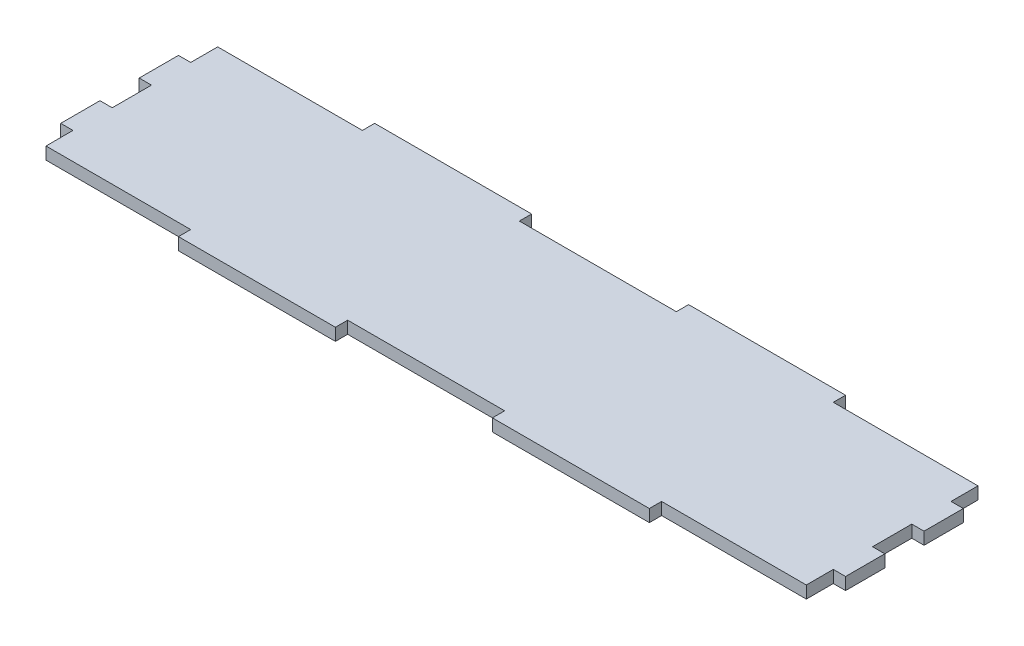
from build123d import *

# Parameters (mm, degrees)
SKETCH1_W           = 203.2
SKETCH1_H           = 50.8
BOSS_EXTRUDE1_DEPTH = 3.175
SKETCH2_W           = 40.64
SKETCH2_H           = 3.175
CUT_EXTRUDE2_DEPTH  = 3.175
LPATTERN1_COUNT     = 3
LPATTERN1_PITCH     = 81.28
SKETCH3_W           = 3.175
SKETCH3_H           = 10.16
CUT_EXTRUDE3_DEPTH  = 3.175
LPATTERN2_COUNT     = 2
LPATTERN2_PITCH     = 20.32
LPATTERN3_COUNT     = 2
LPATTERN3_PITCH     = 20.32


with BuildPart() as part:
    # Sketch1 → Boss-Extrude1 (new body)
    with BuildSketch(Plane(origin=(0, 0, 0), x_dir=(1, 0, 0), z_dir=(0, 1, 0))):
        Rectangle(SKETCH1_W, SKETCH1_H)
    extrude(amount=BOSS_EXTRUDE1_DEPTH)

    # Sketch2 → Cut-Extrude2 (cut)
    with BuildSketch(Plane(origin=(0, 3.175, 0), x_dir=(1, 0, 0), z_dir=(0, 1, 0))):
        with Locations((-81.28, 23.8125)):
            Rectangle(SKETCH2_W, SKETCH2_H)
        with Locations((-81.28, -23.8125)):
            Rectangle(SKETCH2_W, SKETCH2_H)
    cut_extrude2 = extrude(amount=-CUT_EXTRUDE2_DEPTH, mode=Mode.SUBTRACT)

    # LPattern1: Cut-Extrude2 ×3
    with Locations(*[(i * LPATTERN1_PITCH, 0, 0) for i in range(1, LPATTERN1_COUNT)]):
        add(cut_extrude2, mode=Mode.SUBTRACT)

    # Sketch3 → Cut-Extrude3 (cut)
    with BuildSketch(Plane(origin=(0, 3.175, 0), x_dir=(1, 0, 0), z_dir=(0, 1, 0))):
        with Locations((-100.0125, 0)):
            Rectangle(SKETCH3_W, SKETCH3_H)
        with Locations((100.0125, 0)):
            Rectangle(SKETCH3_W, SKETCH3_H)
    cut_extrude3 = extrude(amount=-CUT_EXTRUDE3_DEPTH, mode=Mode.SUBTRACT)

    # LPattern2: Cut-Extrude3 ×2
    with Locations(*[(0, 0, i * LPATTERN2_PITCH) for i in range(1, LPATTERN2_COUNT)]):
        add(cut_extrude3, mode=Mode.SUBTRACT)

    # LPattern3: Cut-Extrude3 ×2
    with Locations(*[(0, 0, -i * LPATTERN3_PITCH) for i in range(1, LPATTERN3_COUNT)]):
        add(cut_extrude3, mode=Mode.SUBTRACT)


solid = part.part
